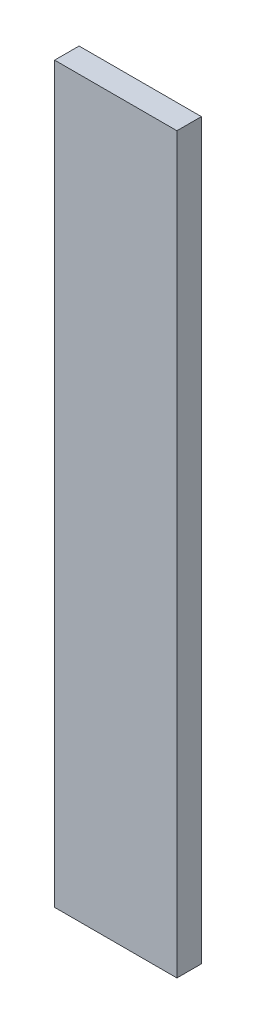
from build123d import *

# Parameters (mm, degrees)
ESQUISSE1_W        = 50
ESQUISSE1_H        = 300
BOSS_EXTRU_1_DEPTH = 10


with BuildPart() as part:
    # Esquisse1 → Boss.-Extru.1 (new body)
    with BuildSketch(Plane.XY):
        with Locations((25, 150)):
            Rectangle(ESQUISSE1_W, ESQUISSE1_H)
    extrude(amount=BOSS_EXTRU_1_DEPTH)


solid = part.part
